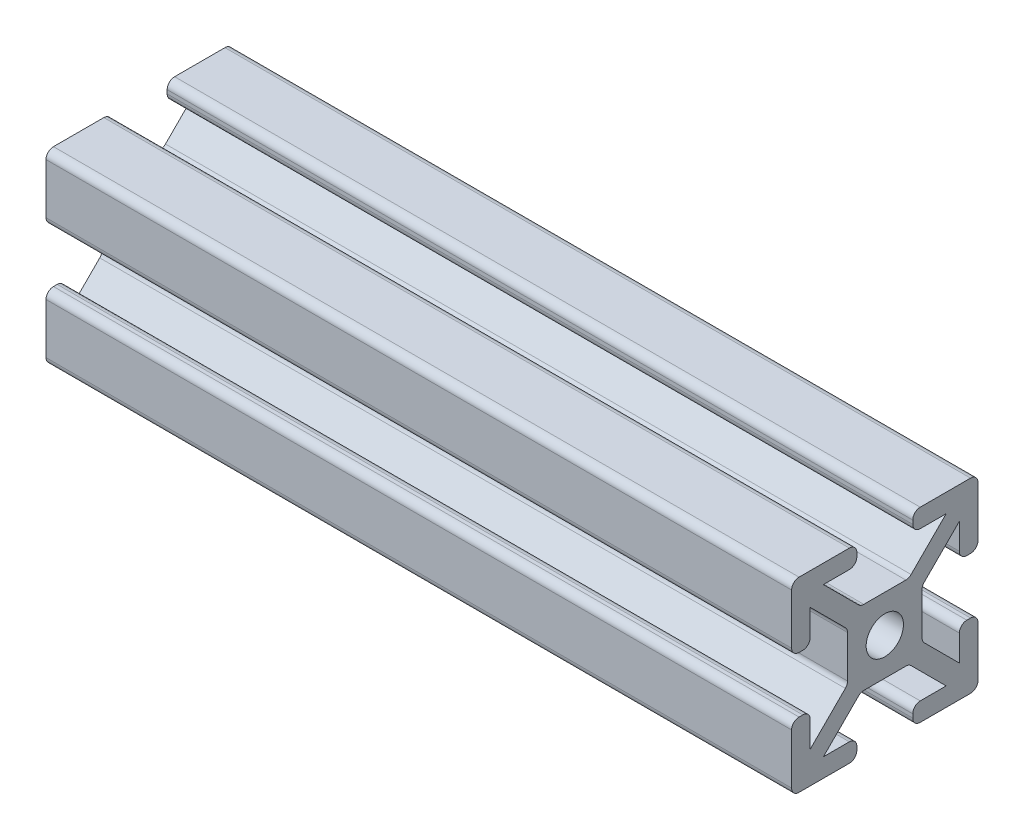
from build123d import *

# Parameters (mm, degrees)
SKETCH11_R          = 2
PROFILE_4X4_1_DEPTH = 80


with BuildPart() as part:
    # Sketch11 → Profile 4X4(1) (new body)
    with BuildSketch(Plane.YZ.offset(-35.597484277)):
        with BuildLine():
            Line((-3, 9.2), (-3, 8.8))
            ThreePointArc((-3, 8.8), (-3.234314575, 8.234314575), (-3.8, 8))
            Line((-3.8, 8), (-6.585786438, 8))
            Line((-6.585786438, 8), (-2.820101013, 4.234314575))
            ThreePointArc((-2.820101013, 4.234314575), (-2.560562334, 4.060896374), (-2.254415588, 4))
            Line((-2.254415588, 4), (2.254415588, 4))
            ThreePointArc((2.254415588, 4), (2.560562334, 4.060896374), (2.820101013, 4.234314575))
            Line((2.820101013, 4.234314575), (6.585786438, 8))
            Line((6.585786438, 8), (3.8, 8))
            ThreePointArc((3.8, 8), (3.234314575, 8.234314575), (3, 8.8))
            Line((3, 8.8), (3, 9.2))
            ThreePointArc((3, 9.2), (3.234314575, 9.765685425), (3.8, 10))
            Line((3.8, 10), (9.2, 10))
            ThreePointArc((9.2, 10), (9.765685425, 9.765685425), (10, 9.2))
            Line((10, 9.2), (10, 3.8))
            ThreePointArc((10, 3.8), (9.765685425, 3.234314575), (9.2, 3))
            Line((9.2, 3), (8.8, 3))
            ThreePointArc((8.8, 3), (8.234314575, 3.234314575), (8, 3.8))
            Line((8, 3.8), (8, 6.585786438))
            Line((8, 6.585786438), (4.234314575, 2.820101013))
            ThreePointArc((4.234314575, 2.820101013), (4.060896374, 2.560562334), (4, 2.254415588))
            Line((4, 2.254415588), (4, -2.254415588))
            ThreePointArc((4, -2.254415588), (4.060896374, -2.560562334), (4.234314575, -2.820101013))
            Line((4.234314575, -2.820101013), (8, -6.585786438))
            Line((8, -6.585786438), (8, -3.8))
            ThreePointArc((8, -3.8), (8.234314575, -3.234314575), (8.8, -3))
            Line((8.8, -3), (9.2, -3))
            ThreePointArc((9.2, -3), (9.765685425, -3.234314575), (10, -3.8))
            Line((10, -3.8), (10, -9.2))
            ThreePointArc((10, -9.2), (9.765685425, -9.765685425), (9.2, -10))
            Line((9.2, -10), (3.8, -10))
            ThreePointArc((3.8, -10), (3.234314575, -9.765685425), (3, -9.2))
            Line((3, -9.2), (3, -8.8))
            ThreePointArc((3, -8.8), (3.234314575, -8.234314575), (3.8, -8))
            Line((3.8, -8), (6.585786438, -8))
            Line((6.585786438, -8), (2.820101013, -4.234314575))
            ThreePointArc((2.820101013, -4.234314575), (2.560562334, -4.060896374), (2.254415588, -4))
            Line((2.254415588, -4), (-2.254415588, -4))
            ThreePointArc((-2.254415588, -4), (-2.560562334, -4.060896374), (-2.820101013, -4.234314575))
            Line((-2.820101013, -4.234314575), (-6.585786438, -8))
            Line((-6.585786438, -8), (-3.8, -8))
            ThreePointArc((-3.8, -8), (-3.234314575, -8.234314575), (-3, -8.8))
            Line((-3, -8.8), (-3, -9.2))
            ThreePointArc((-3, -9.2), (-3.234314575, -9.765685425), (-3.8, -10))
            Line((-3.8, -10), (-9.2, -10))
            ThreePointArc((-9.2, -10), (-9.765685425, -9.765685425), (-10, -9.2))
            Line((-10, -9.2), (-10, -3.8))
            ThreePointArc((-10, -3.8), (-9.765685425, -3.234314575), (-9.2, -3))
            Line((-9.2, -3), (-8.8, -3))
            ThreePointArc((-8.8, -3), (-8.234314575, -3.234314575), (-8, -3.8))
            Line((-8, -3.8), (-8, -6.585786438))
            Line((-8, -6.585786438), (-4.234314575, -2.820101013))
            ThreePointArc((-4.234314575, -2.820101013), (-4.060896374, -2.560562334), (-4, -2.254415588))
            Line((-4, -2.254415588), (-4, 2.254415588))
            ThreePointArc((-4, 2.254415588), (-4.060896374, 2.560562334), (-4.234314575, 2.820101013))
            Line((-4.234314575, 2.820101013), (-8, 6.585786438))
            Line((-8, 6.585786438), (-8, 3.8))
            ThreePointArc((-8, 3.8), (-8.234314575, 3.234314575), (-8.8, 3))
            Line((-8.8, 3), (-9.2, 3))
            ThreePointArc((-9.2, 3), (-9.765685425, 3.234314575), (-10, 3.8))
            Line((-10, 3.8), (-10, 9.2))
            ThreePointArc((-10, 9.2), (-9.765685425, 9.765685425), (-9.2, 10))
            Line((-9.2, 10), (-3.8, 10))
            ThreePointArc((-3.8, 10), (-3.234314575, 9.765685425), (-3, 9.2))
        make_face()
        Circle(SKETCH11_R, mode=Mode.SUBTRACT)
    extrude(amount=PROFILE_4X4_1_DEPTH)


solid = part.part
